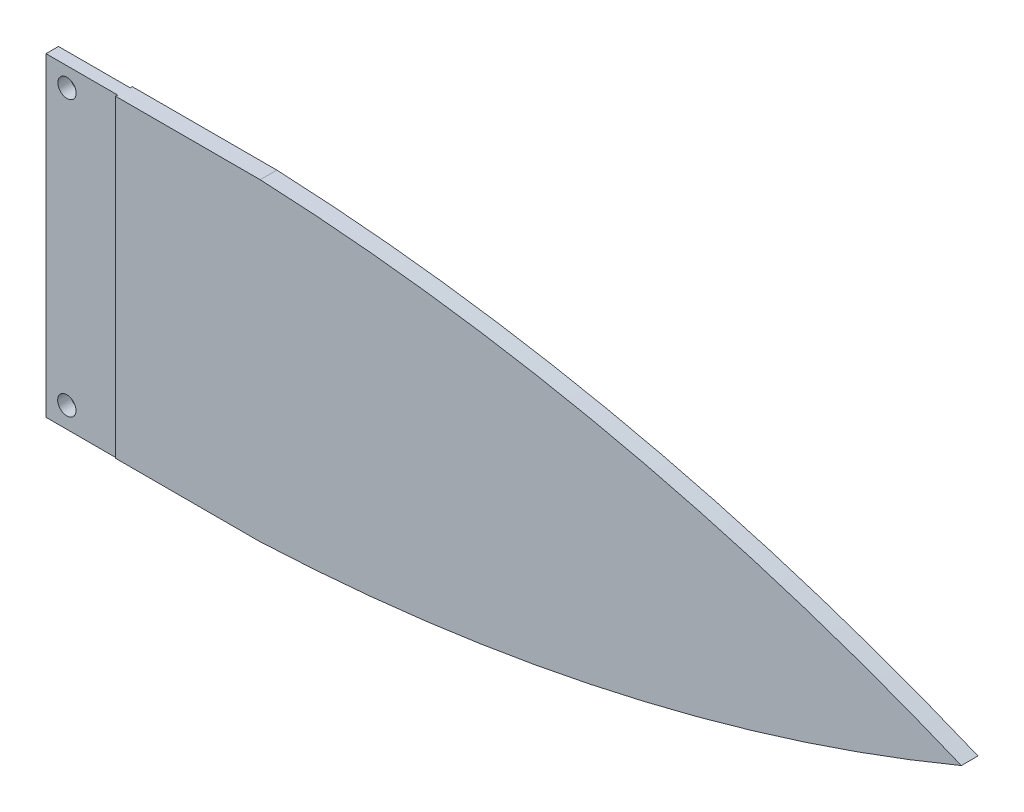
from build123d import *

# Parameters (mm, degrees)
EXTRUDE_1_DEPTH          = 0.75
EXTRUDE_1_DEPTH_BACK     = 0.75
SKETCH_1_W               = 10
SKETCH_1_H               = 38
SKETCH_1_R               = 1.1
SKETCH_3_W               = 20
SKETCH_3_H               = 38.036879249
EXTRUDE_2_DEPTH          = 1.5
EXTRUDE_3_DEPTH          = 1
EXTRUDE_3_DEPTH_BACK     = 1
CUT_EXTRUDE_4_DEPTH      = 0.2
CUT_EXTRUDE_4_DEPTH_BACK = 0.2
SKETCH_10_W              = 112.497058814
SKETCH_10_H              = 20.543414641
CUT_EXTRUDE_5_DEPTH      = 0.2
CUT_EXTRUDE_5_DEPTH_BACK = 0.2
SKETCH_11_W              = 104.514605189
SKETCH_11_H              = 21.657747512
SKETCH_12_W              = 1.5
SKETCH_12_H              = 9
CUT_EXTRUDE_6_DEPTH      = 39


with BuildPart() as part:
    # 草圖1 → 填料-伸長1 (new, two sides: drawn at the far end of the back side and taken through both)
    with BuildSketch(Plane.XY.offset(-EXTRUDE_1_DEPTH_BACK)):
        with Locations((-4.101832994, 0.735234216)):
            Rectangle(SKETCH_1_W, SKETCH_1_H)
        with Locations((-6.601832994, -15.764765784)):
            Circle(SKETCH_1_R, mode=Mode.SUBTRACT)
        with Locations((-6.578411405, 17.235234216)):
            Circle(SKETCH_1_R, mode=Mode.SUBTRACT)
    extrude(amount=EXTRUDE_1_DEPTH + EXTRUDE_1_DEPTH_BACK)

    # 草圖3 → 填料-伸長2 (add)
    with BuildSketch(Plane(origin=(-0.5, 0, 0), x_dir=(0, 0, -1), z_dir=(1, 0, 0))):
        with Locations((0, 0.716794592)):
            Rectangle(SKETCH_3_W, SKETCH_3_H)
    extrude(amount=EXTRUDE_2_DEPTH)

    # 草圖4 → 填料-伸長3 (add, two sides: drawn at the far end of the back side and taken through both)
    with BuildSketch(Plane.XY.offset(-EXTRUDE_3_DEPTH_BACK)):
        with BuildLine():
            Line((1, 19.735234216), (1, -18.298860138))
            ThreePointArc((1, -18.298860138), (51.989546932, -13.993809638), (101, 0.718187039))
            ThreePointArc((101, 0.718187039), (51.989546932, 15.430183716), (1, 19.735234216))
        make_face()
    extrude(amount=EXTRUDE_3_DEPTH + EXTRUDE_3_DEPTH_BACK)

    # 草圖10 → 除料-伸長4 (cut, two sides: drawn at the far end of the back side and taken through both)
    with BuildSketch(Plane(origin=(0, 19.735234216, 0), x_dir=(1, 0, 0), z_dir=(0, 1, 0)).offset(-CUT_EXTRUDE_4_DEPTH_BACK)):
        with Locations((46.49437126, 0.271707321)):
            Rectangle(SKETCH_10_W, SKETCH_10_H)
    extrude(amount=CUT_EXTRUDE_4_DEPTH + CUT_EXTRUDE_4_DEPTH_BACK, mode=Mode.SUBTRACT)

    # 草圖11 → 除料-伸長5 (cut, two sides: drawn at the far end of the back side and taken through both)
    with BuildSketch(Plane(origin=(0, -18.301645033, 0), x_dir=(-1, 0, 0), z_dir=(0, -1, 0)).offset(-CUT_EXTRUDE_5_DEPTH_BACK)):
        with Locations((-51.541283716, 0.828873756)):
            Rectangle(SKETCH_11_W, SKETCH_11_H)
    extrude(amount=CUT_EXTRUDE_5_DEPTH + CUT_EXTRUDE_5_DEPTH_BACK, mode=Mode.SUBTRACT)

    # 草圖12 → 除料-伸長6 (cut)
    with BuildSketch(Plane(origin=(0, 19.735234216, 0), x_dir=(1, 0, 0), z_dir=(0, 1, 0))):
        with Locations((0.25, -5.5)):
            Rectangle(SKETCH_12_W, SKETCH_12_H)
        with Locations((0.25, 5.5)):
            Rectangle(SKETCH_12_W, SKETCH_12_H)
    extrude(amount=-CUT_EXTRUDE_6_DEPTH, mode=Mode.SUBTRACT)


solid = part.part
